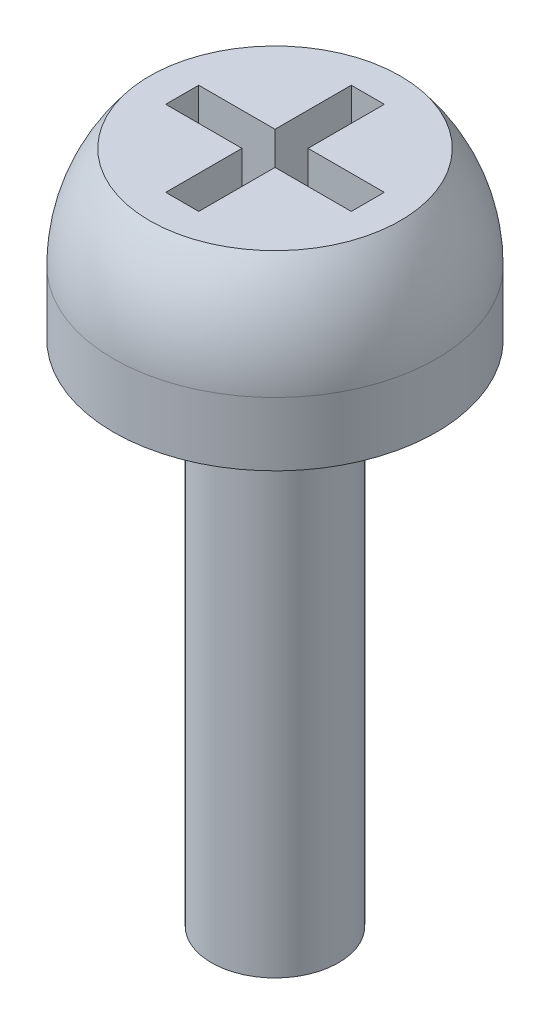
from build123d import *

# Parameters (mm, degrees)
SKETCH1_R           = 1.27
BOSS_EXTRUDE1_DEPTH = 0.5
REVOLVE1_ANGLE      = 180
SKETCH4_R           = 2.5
CUT_EXTRUDE2_DEPTH  = 1.016
CUT_EXTRUDE3_DEPTH  = 1.016
SKETCH6_R           = 0.5
BOSS_EXTRUDE2_DEPTH = 4


with BuildPart() as part:
    # Sketch1 → Boss-Extrude1 (new body)
    with BuildSketch(Plane(origin=(0, 0, 0), x_dir=(1, 0, 0), z_dir=(0, 1, 0))):
        Circle(SKETCH1_R)
    extrude(amount=BOSS_EXTRUDE1_DEPTH)

    # Sketch2 → Revolve1 (revolve)
    with BuildSketch(Plane(origin=(0, 0.5, 0), x_dir=(1, 0, 0), z_dir=(0, 1, 0))):
        with BuildLine():
            Line((0, 1.27), (0, -1.27))
            ThreePointArc((0, -1.27), (-1.27, 0), (0, 1.27))
        make_face()
    revolve(axis=Axis((0, 0.5, -1.27), (0, 0, -1)), revolution_arc=REVOLVE1_ANGLE)

    # Sketch4 → Cut-Extrude2 (cut)
    with BuildSketch(Plane(origin=(0, 1.3, 0), x_dir=(-1, 0, 0), z_dir=(0, -1, 0))):
        Circle(SKETCH4_R)
    extrude(amount=-CUT_EXTRUDE2_DEPTH, mode=Mode.SUBTRACT)

    # Sketch5 → Cut-Extrude3 (cut)
    with BuildSketch(Plane(origin=(0, 1.3, 0), x_dir=(-1, 0, 0), z_dir=(0, -1, 0))):
        Polygon((0.13, 0.13), (0.13, 0.73), (-0.13, 0.73), (-0.13, 0.13), (-0.73, 0.13), (-0.73, -0.13), (-0.13, -0.13), (-0.13, -0.73), (0.13, -0.73), (0.13, -0.13), (0.73, -0.13), (0.73, 0.13), align=None)
    extrude(amount=CUT_EXTRUDE3_DEPTH, mode=Mode.SUBTRACT)

    # Sketch6 → Boss-Extrude2 (add)
    with BuildSketch(Plane.XZ):
        Circle(SKETCH6_R)
    extrude(amount=BOSS_EXTRUDE2_DEPTH)


solid = part.part
